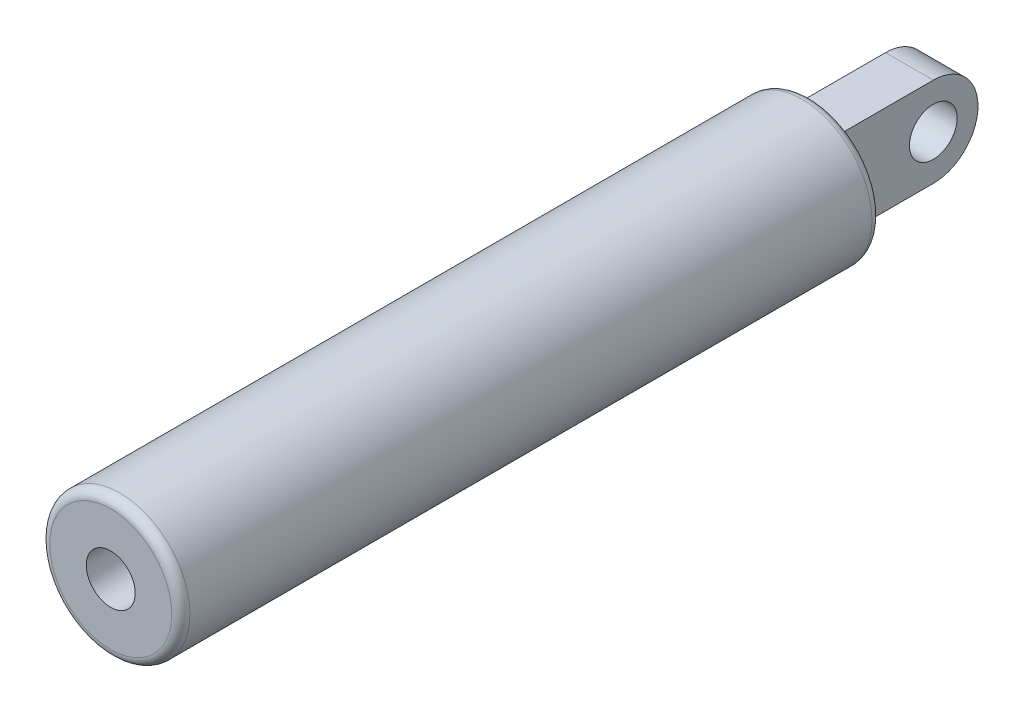
from build123d import *

# Parameters (mm, degrees)
FILLET2_R               = 0.77724
SKETCH2_R               = 2.032
EXTRUDE2_DEPTH          = 2.032
SKETCH9_W               = 42.2148
SKETCH9_H               = 2.032
SKETCH12_R              = 2.032
CUT_EXTRUDE1_DEPTH      = 6.9690001
CUT_EXTRUDE1_DEPTH_BACK = 6.9690001
SKETCH13_OUTSIDE_W      = 37.724
SKETCH13_OUTSIDE_H      = 37.724
SKETCH13_OUTSIDE_W_2    = 4.064
SKETCH13_OUTSIDE_H_2    = 7.874
CUT_EXTRUDE2_DEPTH      = 4.937
CUT_EXTRUDE2_DEPTH_BACK = 6.096
LPATTERN1_COUNT         = 2
LPATTERN1_PITCH         = 29.972


with BuildPart() as part:
    # Sketch1 → Revolve1 (revolve)
    with BuildSketch(Plane(origin=(0, 0, 0), x_dir=(0, 0, -1), z_dir=(1, 0, 0))):
        Polygon((46.609, 0), (46.609, 5.969), (-13.0302, 5.969), (-13.0302, 2.0828), (16.9926, 2.0828), (29.1846, 2.0828), (29.1846, 0), align=None)
    revolve(axis=Axis((0, 0, 54.991), (0, 0, -1)))

    # Fillet2
    fillet2_edges = [part.edges().sort_by_distance(p)[0] for p in [
        (0, -5.969, 13.0302),
        (0, -5.969, -46.609),
    ]]
    fillet(fillet2_edges, radius=FILLET2_R)

    # Sketch2 → Extrude2 (add, symmetric)
    with BuildSketch(Plane(origin=(0, 0, 0), x_dir=(0, 0, -1), z_dir=(1, 0, 0))):
        with BuildLine():
            Line((46.609, 3.81), (54.991, 3.81))
            ThreePointArc((54.991, 3.81), (58.801, 0), (54.991, -3.81))
            Line((54.991, -3.81), (46.609, -3.81))
            Line((46.609, -3.81), (46.609, 3.81))
        make_face()
        with Locations((54.991, 0)):
            Circle(SKETCH2_R, mode=Mode.SUBTRACT)
    extrude(amount=EXTRUDE2_DEPTH, both=True)


with BuildPart() as body_2:
    # Sketch9 → Revolve5 (revolve)
    with BuildSketch(Plane(origin=(0, 0, 0), x_dir=(0, 0, -1), z_dir=(1, 0, 0))):
        with Locations((-21.9456, 1.016)):
            Rectangle(SKETCH9_W, SKETCH9_H)
    revolve(axis=Axis((0, 0, 43.053), (0, 0, 1)))

    # Sketch11 → Revolve6 (revolve)
    with BuildSketch(Plane(origin=(0, 0, 0), x_dir=(0, 0, -1), z_dir=(1, 0, 0))):
        with BuildLine():
            Line((-43.053, 0), (-43.053, 3.937))
            Line((-43.053, 3.937), (-54.991, 3.937))
            ThreePointArc((-54.991, 3.937), (-57.774879398, 2.783879398), (-58.928, 0))
            Line((-58.928, 0), (-43.053, 0))
        make_face()
    revolve(axis=Axis((0, 0, 58.928), (0, 0, 1)))

    # Sketch12 → Cut-Extrude1 (cut, two sides)
    with BuildSketch(Plane(origin=(0, 0, 0), x_dir=(0, 0, -1), z_dir=(1, 0, 0))) as cut_extrude1_sk:
        with Locations((-54.991, 0)):
            Circle(SKETCH12_R)
    extrude(amount=CUT_EXTRUDE1_DEPTH, mode=Mode.SUBTRACT)
    extrude(cut_extrude1_sk.sketch, amount=-CUT_EXTRUDE1_DEPTH_BACK, mode=Mode.SUBTRACT)

    # Sketch13 outside → Cut-Extrude2 (cut, two sides)
    with BuildSketch(Plane.XY.offset(54.991)) as cut_extrude2_sk:
        Rectangle(SKETCH13_OUTSIDE_W, SKETCH13_OUTSIDE_H)
        Rectangle(SKETCH13_OUTSIDE_W_2, SKETCH13_OUTSIDE_H_2, mode=Mode.SUBTRACT)
    extrude(amount=CUT_EXTRUDE2_DEPTH, mode=Mode.SUBTRACT)
    extrude(cut_extrude2_sk.sketch, amount=-CUT_EXTRUDE2_DEPTH_BACK, mode=Mode.SUBTRACT)


with BuildPart() as lpattern1_1:
    # LPattern1: pattern copy
    add(body_2.part.moved(Location(Vector(0, 0, -1) * (1 * LPATTERN1_PITCH))))


solid = part.part
